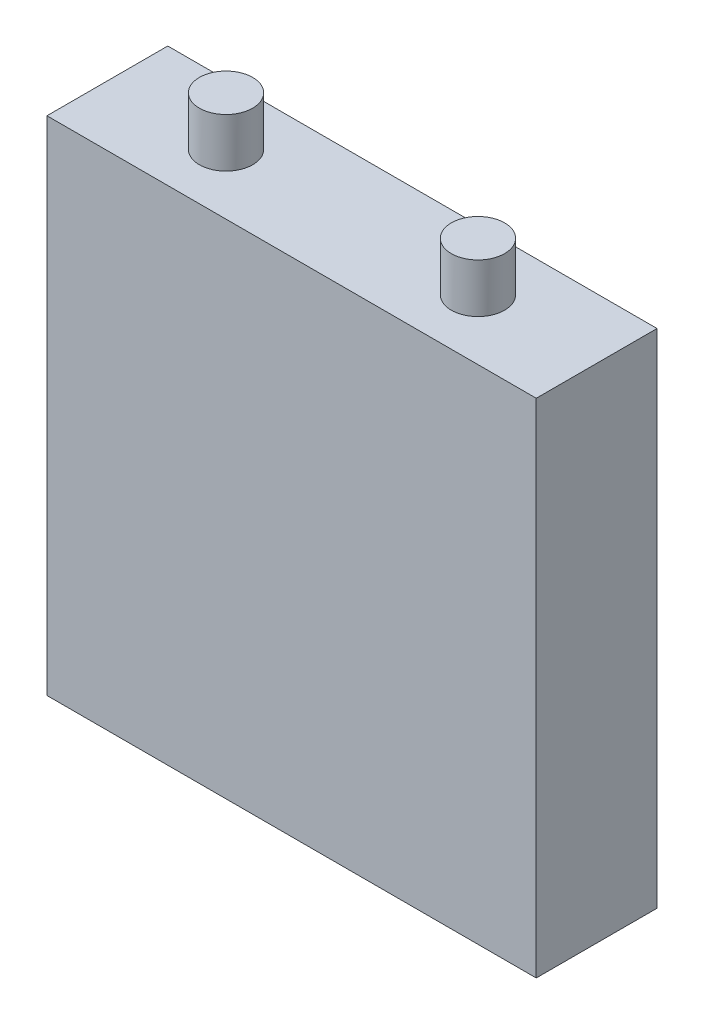
from build123d import *

# Parameters (mm, degrees)
SKETCH1_W           = 137.7
SKETCH1_H           = 34
BOSS_EXTRUDE1_DEPTH = 141.3
SKETCH2_R           = 7.5
BOSS_EXTRUDE2_DEPTH = 13.8


with BuildPart() as part:
    # Sketch1 → Boss-Extrude1 (new body)
    with BuildSketch(Plane(origin=(0, 0, 0), x_dir=(1, 0, 0), z_dir=(0, 1, 0))):
        with Locations((68.85, 17)):
            Rectangle(SKETCH1_W, SKETCH1_H)
    extrude(amount=BOSS_EXTRUDE1_DEPTH)

    # Sketch2 → Boss-Extrude2 (add)
    with BuildSketch(Plane(origin=(0, 141.3, 0), x_dir=(1, 0, 0), z_dir=(0, 1, 0))):
        with Locations((33.4, 17)):
            Circle(SKETCH2_R)
        with Locations((104.3, 17)):
            Circle(SKETCH2_R)
    extrude(amount=BOSS_EXTRUDE2_DEPTH)


solid = part.part
